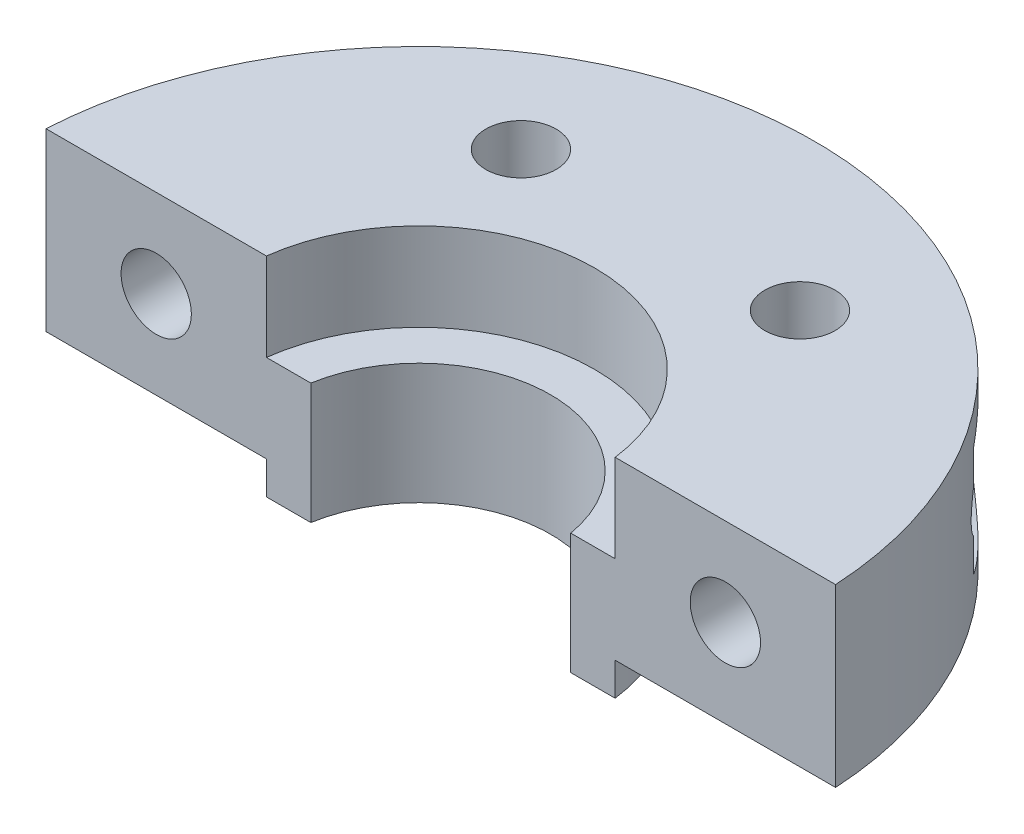
from build123d import *

# Parameters (mm, degrees)
SKETCH1_R           = 18
SKETCH1_R_2         = 8
SKETCH1_R_3         = 1.6
BOSS_EXTRUDE1_DEPTH = 8
SKETCH2_R           = 8
SKETCH2_R_2         = 6
BOSS_EXTRUDE2_DEPTH = 5.5
SKETCH3_W           = 40
SKETCH3_H           = 20
CUT_EXTRUDE1_DEPTH  = 10.5
CUT_EXTRUDE2_REACH  = 19
SKETCH5_R           = 1.6
CUT_EXTRUDE3_REACH  = 29
CUT_EXTRUDE3_START  = -10
SKETCH6_R           = 2.8


with BuildPart() as part:
    # Sketch1 → Boss-Extrude1 (new body)
    with BuildSketch(Plane(origin=(0, 0, 0), x_dir=(1, 0, 0), z_dir=(0, 1, 0))):
        Circle(SKETCH1_R)
        Circle(SKETCH1_R_2, mode=Mode.SUBTRACT)
        with Locations((-6.350852961, 11)):
            Circle(SKETCH1_R_3, mode=Mode.SUBTRACT)
        with Locations((6.350852961, 11)):
            Circle(SKETCH1_R_3, mode=Mode.SUBTRACT)
    extrude(amount=BOSS_EXTRUDE1_DEPTH)

    # Sketch2 → Boss-Extrude2 (add)
    with BuildSketch(Plane(origin=(0, 4, 0), x_dir=(1, 0, 0), z_dir=(0, 1, 0))):
        Circle(SKETCH2_R)
        Circle(SKETCH2_R_2, mode=Mode.SUBTRACT)
    extrude(amount=-BOSS_EXTRUDE2_DEPTH)

    # Sketch3 → Cut-Extrude1 (cut, through all)
    with BuildSketch(Plane(origin=(0, 8, 0), x_dir=(1, 0, 0), z_dir=(0, 1, 0))):
        with Locations((0, -9)):
            Rectangle(SKETCH3_W, SKETCH3_H)
    extrude(amount=-CUT_EXTRUDE1_DEPTH, mode=Mode.SUBTRACT)

    # Sketch5 → Cut-Extrude2 (cut, up to next)
    with BuildSketch(Plane.XY.offset(-1), mode=Mode.PRIVATE) as cut_extrude2_sk1:
        with Locations((-12.954727344, 4)):
            Circle(SKETCH5_R)
    cut_extrude2_tool1 = extrude(cut_extrude2_sk1.sketch, amount=-CUT_EXTRUDE2_REACH, mode=Mode.PRIVATE) & part.part
    add(cut_extrude2_tool1.solids().sort_by_distance((-12.954727, 4, -1))[0], mode=Mode.SUBTRACT)
    # Sketch5 → Cut-Extrude2 (cut, up to next)
    with BuildSketch(Plane.XY.offset(-1), mode=Mode.PRIVATE) as cut_extrude2_sk2:
        with Locations((12.954727344, 4)):
            Circle(SKETCH5_R)
    cut_extrude2_tool2 = extrude(cut_extrude2_sk2.sketch, amount=-CUT_EXTRUDE2_REACH, mode=Mode.PRIVATE) & part.part
    add(cut_extrude2_tool2.solids().sort_by_distance((12.954727, 4, -1))[0], mode=Mode.SUBTRACT)

    # Sketch6 → Cut-Extrude3 (cut, up to next)
    with BuildSketch(Plane.XY.offset(-1).offset(CUT_EXTRUDE3_START), mode=Mode.PRIVATE) as cut_extrude3_sk1:
        with Locations((-12.954727344, 4)):
            Circle(SKETCH6_R)
    cut_extrude3_tool1 = extrude(cut_extrude3_sk1.sketch, amount=-CUT_EXTRUDE3_REACH, mode=Mode.PRIVATE) & part.part
    add(cut_extrude3_tool1.solids().sort_by_distance((-12.954727, 4, -11))[0], mode=Mode.SUBTRACT)
    # Sketch6 → Cut-Extrude3 (cut, up to next)
    with BuildSketch(Plane.XY.offset(-1).offset(CUT_EXTRUDE3_START), mode=Mode.PRIVATE) as cut_extrude3_sk2:
        with Locations((12.954727344, 4)):
            Circle(SKETCH6_R)
    cut_extrude3_tool2 = extrude(cut_extrude3_sk2.sketch, amount=-CUT_EXTRUDE3_REACH, mode=Mode.PRIVATE) & part.part
    add(cut_extrude3_tool2.solids().sort_by_distance((12.954727, 4, -11))[0], mode=Mode.SUBTRACT)


solid = part.part
